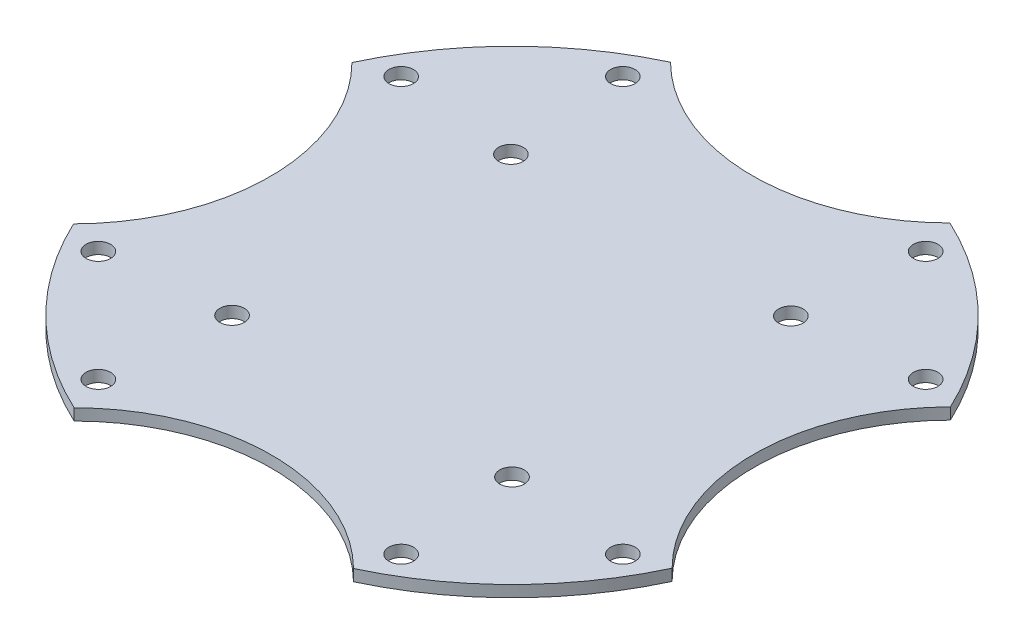
from build123d import *

# Parameters (mm, degrees)
SKETCH2_R           = 1.6
BOSS_EXTRUDE1_DEPTH = 1.5


with BuildPart() as part:
    # Sketch2 → Boss-Extrude1 (new body)
    with BuildSketch(Plane(origin=(0, 0, 0), x_dir=(1, 0, 0), z_dir=(0, 1, 0))):
        with BuildLine():
            ThreePointArc((-18.257935671, 38.931321388), (-30.460746389, 30.350336562), (-38.99736345, 18.116446781))
            ThreePointArc((-38.99736345, 18.116446781), (-31.450297137, -0.057101793), (-38.931321388, -18.257935671))
            ThreePointArc((-38.931321388, -18.257935671), (-30.350336562, -30.460746389), (-18.116446781, -38.99736345))
            ThreePointArc((-18.116446781, -38.99736345), (0.057101793, -31.450297137), (18.257935671, -38.931321388))
            ThreePointArc((18.257935671, -38.931321388), (30.460746389, -30.350336562), (38.99736345, -18.116446781))
            ThreePointArc((38.99736345, -18.116446781), (31.450297137, 0.057101793), (38.931321388, 18.257935671))
            ThreePointArc((38.931321388, 18.257935671), (30.350336562, 30.460746389), (18.116446781, 38.99736345))
            ThreePointArc((18.116446781, 38.99736345), (-0.057101793, 31.450297137), (-18.257935671, 38.931321388))
        make_face()
        with Locations((19.75, 34.208003449)):
            Circle(SKETCH2_R, mode=Mode.SUBTRACT)
        with Locations((34.208003449, 19.75)):
            Circle(SKETCH2_R, mode=Mode.SUBTRACT)
        with Locations((19.75, -34.208003449)):
            Circle(SKETCH2_R, mode=Mode.SUBTRACT)
        with Locations((34.208003449, -19.75)):
            Circle(SKETCH2_R, mode=Mode.SUBTRACT)
        with Locations((-34.208003449, -19.75)):
            Circle(SKETCH2_R, mode=Mode.SUBTRACT)
        with Locations((-19.75, -34.208003449)):
            Circle(SKETCH2_R, mode=Mode.SUBTRACT)
        with Locations((-19.75, 34.208003449)):
            Circle(SKETCH2_R, mode=Mode.SUBTRACT)
        with Locations((-34.208003449, 19.75)):
            Circle(SKETCH2_R, mode=Mode.SUBTRACT)
        with Locations((-18.257935671, 18.116446781)):
            Circle(SKETCH2_R, mode=Mode.SUBTRACT)
        with Locations((18.257935671, 18.116446781)):
            Circle(SKETCH2_R, mode=Mode.SUBTRACT)
        with Locations((-18.257935671, -18.257935671)):
            Circle(SKETCH2_R, mode=Mode.SUBTRACT)
        with Locations((18.257935671, -18.257935671)):
            Circle(SKETCH2_R, mode=Mode.SUBTRACT)
    extrude(amount=BOSS_EXTRUDE1_DEPTH)


solid = part.part
